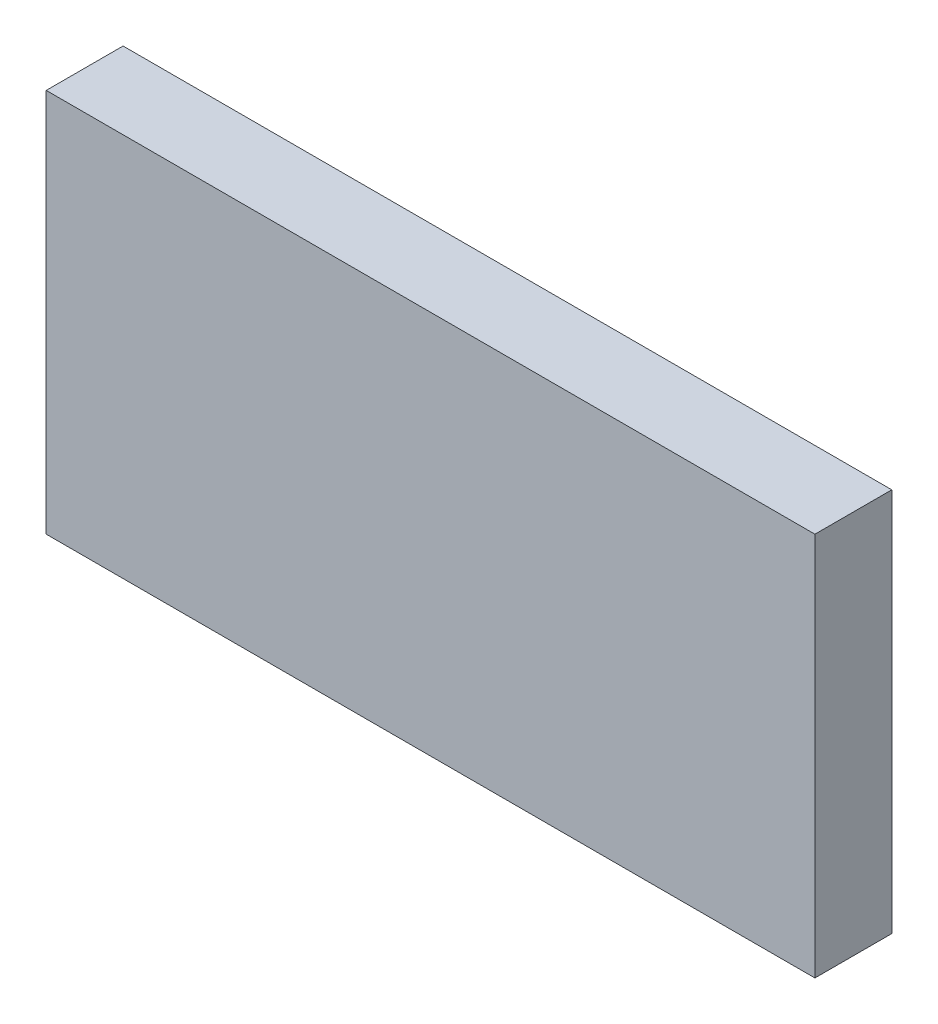
from build123d import *

# Parameters (mm, degrees)
SKETCH1_W           = 30
SKETCH1_H           = 15
BOSS_EXTRUDE1_DEPTH = 3


with BuildPart() as part:
    # Sketch1 → Boss-Extrude1 (new body)
    with BuildSketch(Plane.XY):
        Rectangle(SKETCH1_W, SKETCH1_H)
    extrude(amount=BOSS_EXTRUDE1_DEPTH)


solid = part.part
